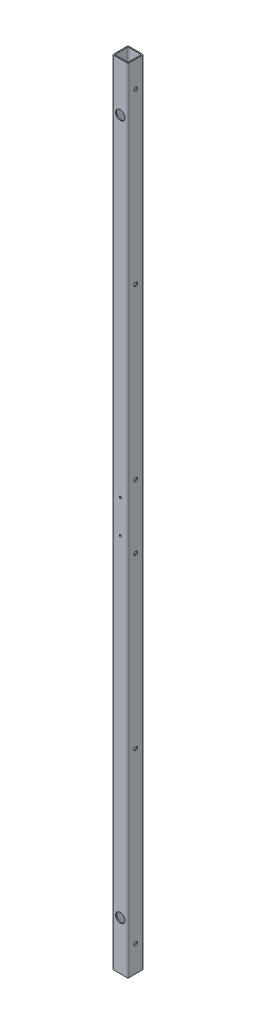
from build123d import *

# Parameters (mm, degrees)
SKETCH1_W                        = 25.4
SKETCH1_H                        = 25.4
SKETCH1_W_2                      = 22.098
SKETCH1_H_2                      = 22.098
BOSS_EXTRUDE1_DEPTH              = 1309.624
FILLET1_R                        = 1.27
F_1_0_228_DIAMETER_HOLE1_D       = 5.7912
F_8_32_TAPPED_HOLE1_D            = 3.4544
F_39_64_0_60938_DIAMETER_HOLE1_D = 15.478252


with BuildPart() as part:
    # Sketch1 → Boss-Extrude1 (new body)
    with BuildSketch(Plane(origin=(0, 0, 0), x_dir=(1, 0, 0), z_dir=(0, 1, 0))):
        Rectangle(SKETCH1_W, SKETCH1_H)
        Rectangle(SKETCH1_W_2, SKETCH1_H_2, mode=Mode.SUBTRACT)
    extrude(amount=BOSS_EXTRUDE1_DEPTH)

    # Fillet1
    fillet1_edges = [part.edges().sort_by_distance(p)[0] for p in [
        (-11.049, 654.812, 11.049),
        (11.049, 654.812, 11.049),
        (11.049, 654.812, -11.049),
        (-11.049, 654.812, -11.049),
        (12.7, 654.812, 12.7),
        (-12.7, 654.812, 12.7),
        (-12.7, 654.812, -12.7),
        (12.7, 654.812, -12.7),
    ]]
    fillet(fillet1_edges, radius=FILLET1_R)

    # #1 (0.228) Diameter Hole1 (through all)
    with Locations(Plane(origin=(12.7, 0, 0), x_dir=(0, 0, -1), z_dir=(1, 0, 0))):
        with Locations((0, 601.98), (0, 1266.444), (0, 987.044), (0, 707.644), (0, 43.18), (0, 322.58)):
            Hole(F_1_0_228_DIAMETER_HOLE1_D / 2)

    # #8-32 Tapped Hole1 (through all)
    with Locations(Plane(origin=(0, 0, -12.7), x_dir=(-1, 0, 0), z_dir=(0, 0, -1))):
        with Locations((0, 627.38), (0, 682.244)):
            Hole(F_8_32_TAPPED_HOLE1_D / 2)

    # 39/64 (0.60938) Diameter Hole1 (through all)
    with Locations(Plane.XY.offset(12.7)):
        with Locations((0, 1229.36), (0, 80.264)):
            Hole(F_39_64_0_60938_DIAMETER_HOLE1_D / 2)


solid = part.part
